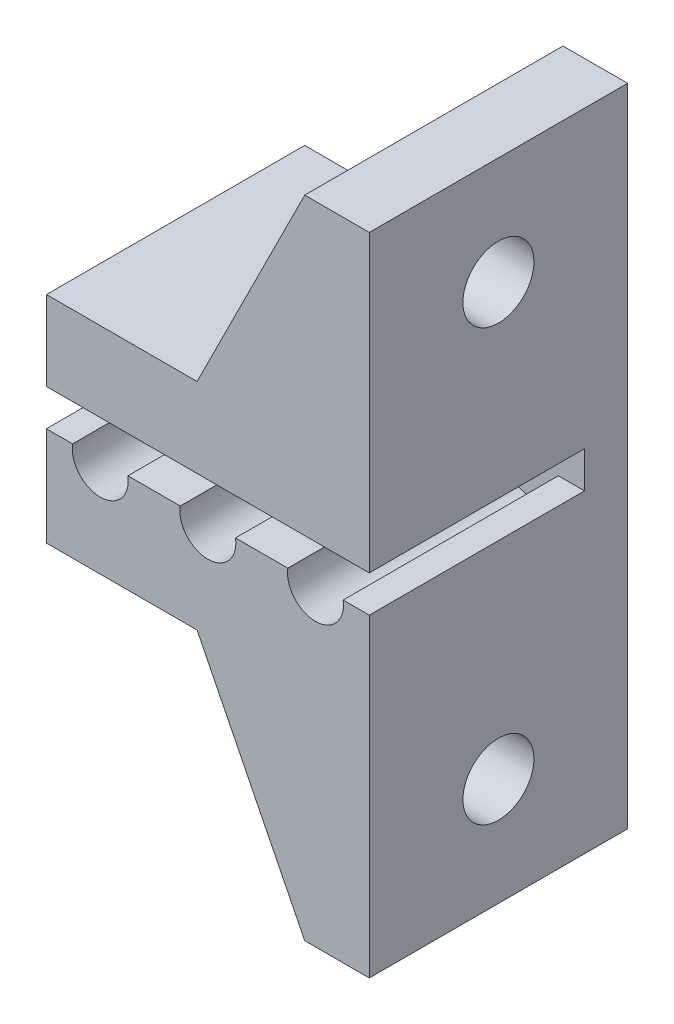
from build123d import *

# Parameters (mm, degrees)
BOSS_EXTRUDE1_DEPTH     = 10
BOSS_EXTRUDE2_DEPTH     = 2
CUT_EXTRUDE1_REACH      = 23.656
SKETCH5_R               = 1.65
RIB1_REACH              = 26.372
SKETCH4_WALL_W          = 61.924570316
SKETCH4_WALL_H          = 1.5
MIRROR2_COPY_1_REACH    = 26.372
MIRROR2_COPY_1_SKETCH_W = 61.924570316
MIRROR2_COPY_1_SKETCH_H = 1.5


with BuildPart() as part:
    # Sketch2 → Boss-Extrude1 (new body)
    with BuildSketch(Plane.XY):
        with BuildLine():
            Line((1, -0.6), (0, -0.6))
            Line((0, -0.6), (0, -5))
            Line((0, -5), (12, -5))
            Line((12, -5), (12, -15))
            Line((12, -15), (15, -15))
            Line((15, -15), (15, -0.6))
            Line((15, -0.6), (14, -0.6))
            ThreePointArc((14, -0.6), (12.5, -2.1), (11, -0.6))
            Line((11, -0.6), (9, -0.6))
            ThreePointArc((9, -0.6), (7.5, -2.1), (6, -0.6))
            Line((6, -0.6), (4, -0.6))
            ThreePointArc((4, -0.6), (2.5, -2.1), (1, -0.6))
        make_face()
        Polygon((12, 5), (0, 5), (0, 1.3), (15, 1.3), (15, 15), (12, 15), align=None)
        with BuildLine():
            Line((1.215476742, -0.4), (0, -0.4))
            Line((0, -0.4), (0, -0.6))
            Line((0, -0.6), (1, -0.6))
            ThreePointArc((1, -0.6), (2.5, -2.1), (4, -0.6))
            Line((4, -0.6), (6, -0.6))
            ThreePointArc((6, -0.6), (7.5, -2.1), (9, -0.6))
            Line((9, -0.6), (11, -0.6))
            ThreePointArc((11, -0.6), (12.5, -2.1), (14, -0.6))
            Line((14, -0.6), (15, -0.6))
            Line((15, -0.6), (15, -0.4))
            Line((15, -0.4), (13.784523258, -0.4))
            ThreePointArc((13.784523258, -0.4), (12.5, -1.9), (11.215476742, -0.4))
            Line((11.215476742, -0.4), (8.784523258, -0.4))
            ThreePointArc((8.784523258, -0.4), (7.5, -1.9), (6.215476742, -0.4))
            Line((6.215476742, -0.4), (3.784523258, -0.4))
            ThreePointArc((3.784523258, -0.4), (2.5, -1.9), (1.215476742, -0.4))
        make_face()
    extrude(amount=BOSS_EXTRUDE1_DEPTH)

    # Sketch2_4 → Boss-Extrude2 (add)
    with BuildSketch(Plane.XY):
        Polygon((0, 5), (0, -5), (12, -5), (12, -15), (15, -15), (15, 15), (12, 15), (12, 5), align=None)
    extrude(amount=-BOSS_EXTRUDE2_DEPTH)

    # Sketch5 → Cut-Extrude1 (cut, up to next)
    with BuildSketch(Plane.ZY.offset(-12), mode=Mode.PRIVATE) as cut_extrude1_sk1:
        with Locations(Location((4, 10, 0), (0, 0, 270))):
            Circle(SKETCH5_R)
    cut_extrude1_tool1 = extrude(cut_extrude1_sk1.sketch, amount=-CUT_EXTRUDE1_REACH, mode=Mode.PRIVATE) & part.part
    cut_extrude1 = cut_extrude1_tool1.solids().sort_by_distance((12, 10, 4))[0]
    add(cut_extrude1, mode=Mode.SUBTRACT)

    # Sketch4 wall → Rib1 (add, up to next)
    with BuildSketch(Plane(origin=(9.5, 10, 10), x_dir=(0.4472135955, 0.894427191, 0), z_dir=(-0.894427191, 0.4472135955, 0)), mode=Mode.PRIVATE) as rib1_sk1:
        with Locations((0, 0.75)):
            Rectangle(SKETCH4_WALL_W, SKETCH4_WALL_H)
    rib1_tool1 = extrude(rib1_sk1.sketch, amount=-RIB1_REACH, mode=Mode.PRIVATE) - part.part
    rib1 = rib1_tool1.solids().sort_by_distance((9.5, 10, 10))[0]
    add(rib1)

    # Mirror1: Rib1 across plane
    add(rib1.mirror(Plane.XY.offset(4)))

    # Mirror2: Cut-Extrude1, Rib1 across plane
    add(cut_extrude1.mirror(Plane.ZX), mode=Mode.SUBTRACT)
    add(rib1.mirror(Plane.ZX))

    # Mirror2 copy 1 sketch → Mirror2 copy 1 (add, up to next)
    with BuildSketch(Plane(origin=(9.5, -10, -2), x_dir=(0.4472135955, -0.894427191, 0), z_dir=(-0.894427191, -0.4472135955, 0)), mode=Mode.PRIVATE) as mirror2_copy_1_sk1:
        with Locations((0, 0.75)):
            Rectangle(MIRROR2_COPY_1_SKETCH_W, MIRROR2_COPY_1_SKETCH_H)
    mirror2_copy_1_tool1 = extrude(mirror2_copy_1_sk1.sketch, amount=-MIRROR2_COPY_1_REACH, mode=Mode.PRIVATE) - part.part
    add(mirror2_copy_1_tool1.solids().sort_by_distance((9.5, -10, -2))[0])


solid = part.part
